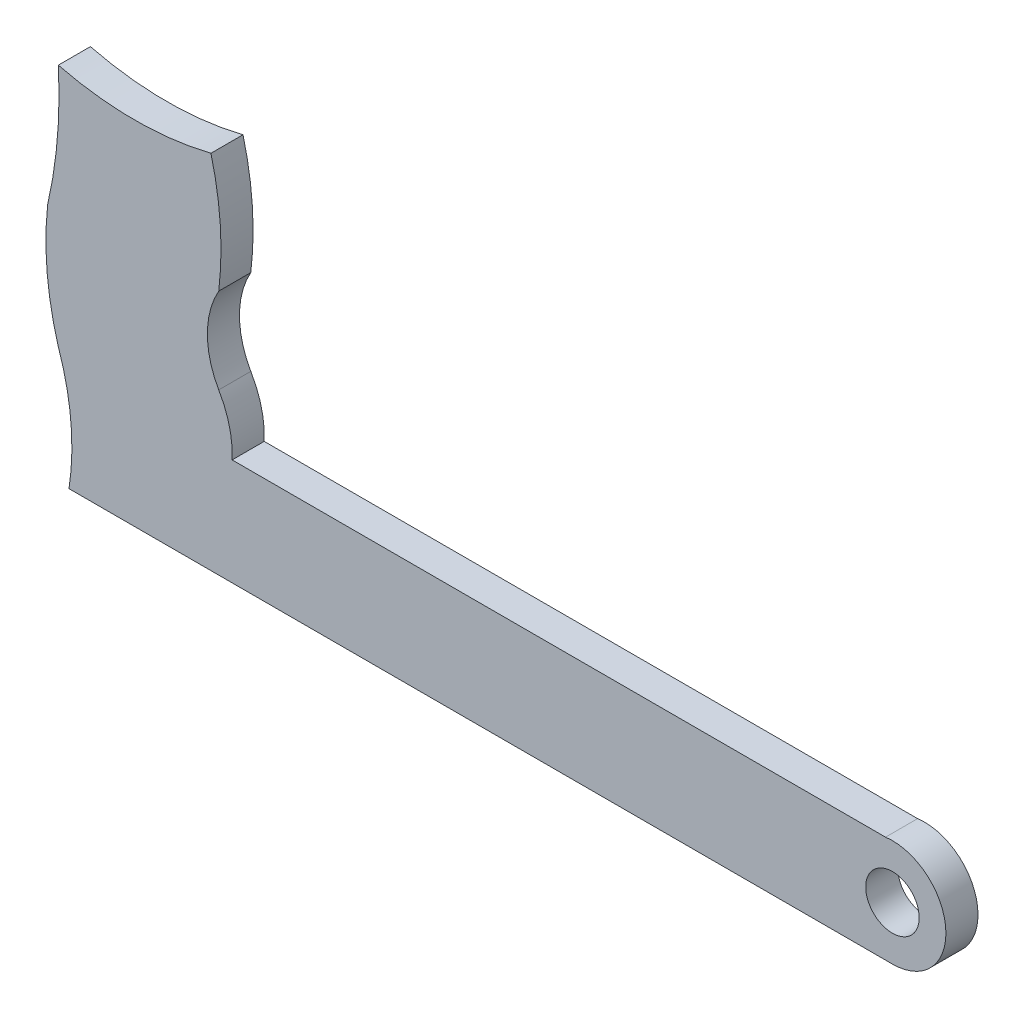
from build123d import *

# Parameters (mm, degrees)
MODEL_R                 = 2.5
SALIENTE_EXTRUIR1_DEPTH = 3


with BuildPart() as part:
    # Model → Saliente-Extruir1 (new body)
    with BuildSketch(Plane.XY):
        with BuildLine():
            Line((11.080118073, 12.100032616), (32.626217211, 12.100005802))
            Line((32.626217211, 12.100005802), (54.087474295, 12.099999973))
            Line((54.087474295, 12.099999973), (88.080119434, 12.099990741))
            ThreePointArc((88.080119434, 12.099990741), (93.069612737, 17.423981681), (87.43349937, 22.058002513))
            Line((87.43349937, 22.058002513), (26.334882576, 22.058035741))
            ThreePointArc((26.334882576, 22.058035741), (26.077271745, 24.671051179), (25.080126231, 27.100025003))
            ThreePointArc((25.080126231, 27.100025003), (24.017870658, 31.10002558), (25.080130581, 35.100025003))
            ThreePointArc((25.080130581, 35.100025003), (25.229028906, 40.534712367), (24.350613381, 45.900006732))
            ThreePointArc((24.350613381, 45.900006732), (17.215374003, 45.022517475), (10.080135103, 45.900010617))
            ThreePointArc((10.080135103, 45.900010617), (9.999432675, 39.964488004), (9.080130038, 34.100033704))
            ThreePointArc((9.080130038, 34.100033704), (9.035519695, 28.550523972), (10.080124055, 23.10003316))
            ThreePointArc((10.080124055, 23.10003316), (11.257202039, 17.661585333), (11.080118073, 12.100032616))
        make_face()
        with Locations((88.080120792, 17.099990741)):
            Circle(MODEL_R, mode=Mode.SUBTRACT)
    extrude(amount=SALIENTE_EXTRUIR1_DEPTH)


solid = part.part
